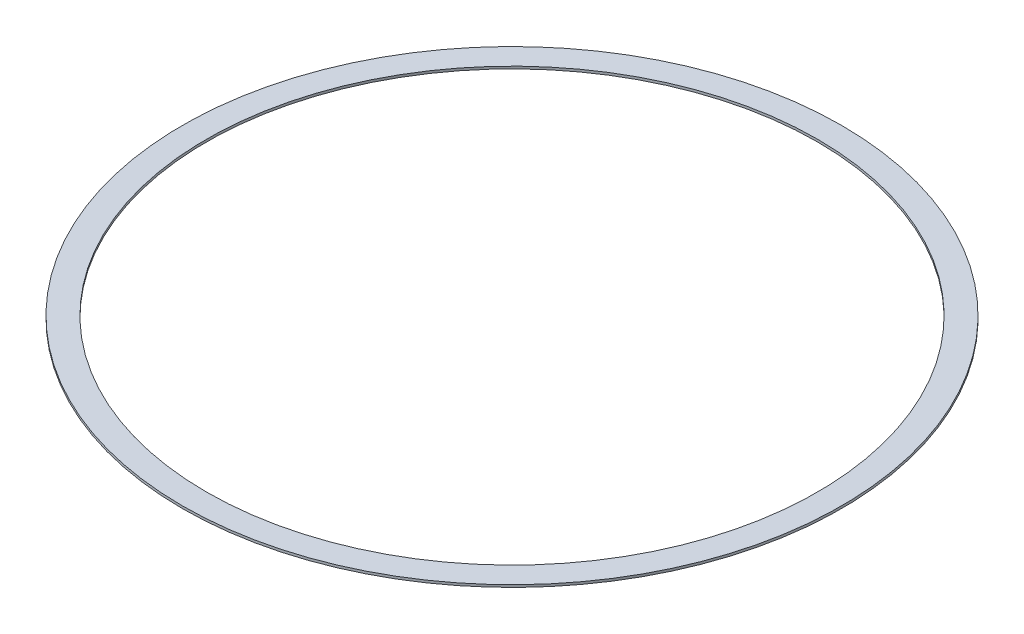
from build123d import *

# Parameters (mm, degrees)
SKETCH_2_R      = 274.629953844
SKETCH_2_R_2    = 254.629953844
EXTRUDE_1_DEPTH = 2


with BuildPart() as part:
    # 草图2 → 凸台-拉伸1 (new body)
    with BuildSketch(Plane(origin=(0, 0, 0), x_dir=(1, 0, 0), z_dir=(0, 1, 0))):
        Circle(SKETCH_2_R)
        Circle(SKETCH_2_R_2, mode=Mode.SUBTRACT)
    extrude(amount=EXTRUDE_1_DEPTH)


solid = part.part
